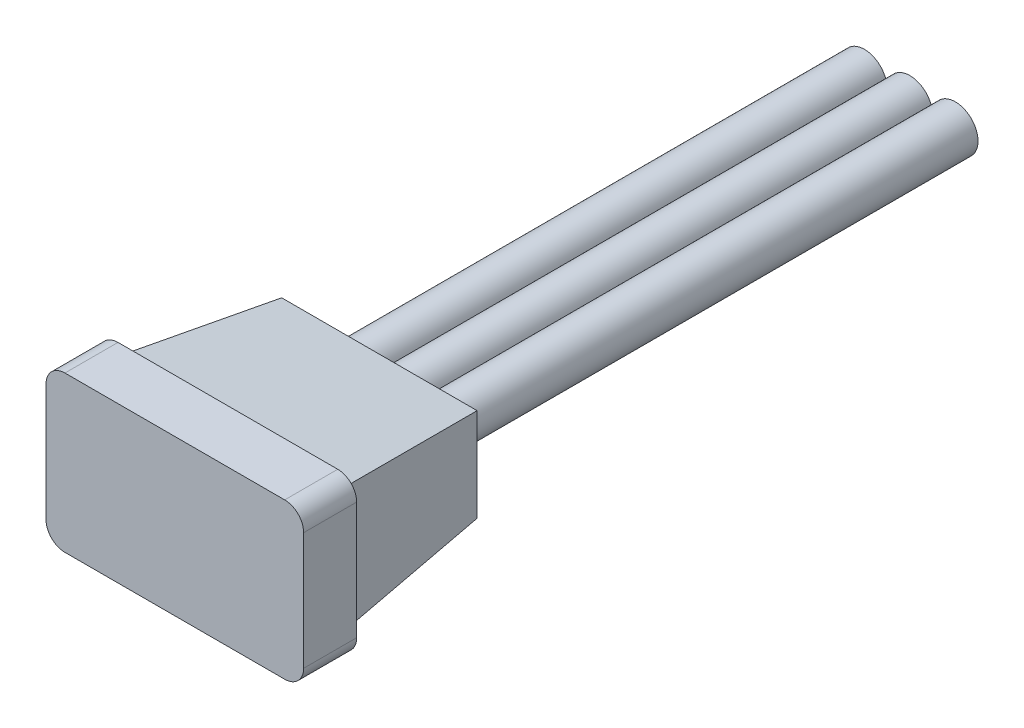
from build123d import *

# Parameters (mm, degrees)
BASES_W             = 6.8
BASES_H             = 4.1
BASE_DEPTH          = 1.4
EXTENDEDBODYS_W     = 6
EXTENDEDBODYS_H     = 3.3
EXTENDED_BODY_DEPTH = 4
EXTENDED_BODY_TAPER = 6
POSITIVES_R         = 0.6
POSITIVE_DEPTH      = 14
SIGNALS_R           = 0.6
SIGNAL_DEPTH        = 14
NEGATIVES_R         = 0.6
NEGATIVE_DEPTH      = 14
BASE_F_R            = 0.5


with BuildPart() as part:
    # BaseS → BASE (new body)
    with BuildSketch(Plane.XY):
        Rectangle(BASES_W, BASES_H)
    extrude(amount=-BASE_DEPTH)

    # ExtendedBodyS → EXTENDED BODY (add)
    with BuildSketch(Plane(origin=(0, 0, -1.4), x_dir=(-1, 0, 0), z_dir=(0, 0, -1))):
        Rectangle(EXTENDEDBODYS_W, EXTENDEDBODYS_H)
    extrude(amount=EXTENDED_BODY_DEPTH, taper=EXTENDED_BODY_TAPER)

    # PositiveS → POSITIVE (add)
    with BuildSketch(Plane(origin=(0, 0, -5.4), x_dir=(-1, 0, 0), z_dir=(0, 0, -1))):
        Circle(POSITIVES_R)
    extrude(amount=POSITIVE_DEPTH)

    # BASE F
    base_f_edges = [part.edges().sort_by_distance(p)[0] for p in [
        (3.4, -2.05, -0.7),
        (-3.4, -2.05, -0.7),
        (-3.4, 2.05, -0.7),
        (3.4, 2.05, -0.7),
    ]]
    fillet(base_f_edges, radius=BASE_F_R)


with BuildPart() as body_2:
    # SignalS → SIGNAL (new body)
    with BuildSketch(Plane(origin=(0, 0, -5.4), x_dir=(-1, 0, 0), z_dir=(0, 0, -1))):
        with Locations((1.2, 0)):
            Circle(SIGNALS_R)
    extrude(amount=SIGNAL_DEPTH)


with BuildPart() as body_3:
    # NegativeS → NEGATIVE (new body)
    with BuildSketch(Plane(origin=(0, 0, -5.4), x_dir=(-1, 0, 0), z_dir=(0, 0, -1))):
        with Locations((-1.2, 0)):
            Circle(NEGATIVES_R)
    extrude(amount=NEGATIVE_DEPTH)


solid = Compound([part.part, body_2.part, body_3.part])
